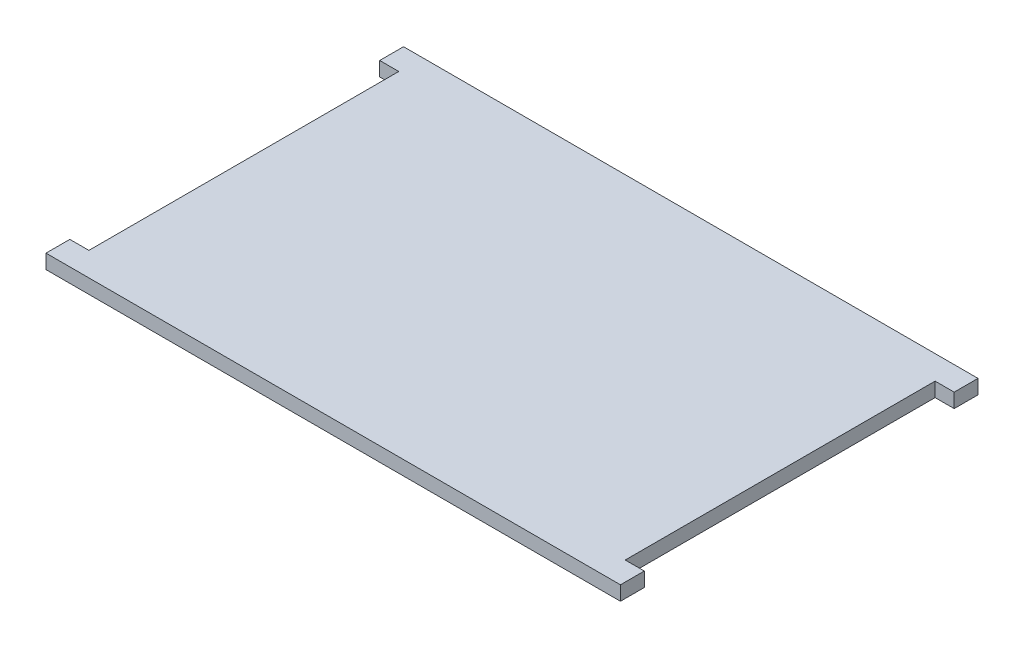
from build123d import *

# Parameters (mm, degrees)
BOSS_EXTRUDE1_DEPTH = 6


with BuildPart() as part:
    # Sketch1 → Boss-Extrude1 (new body)
    with BuildSketch(Plane(origin=(0, 0, 0), x_dir=(1, 0, 0), z_dir=(0, 1, 0))):
        Polygon((-120.5, 75), (120.5, 75), (120.5, 65), (112.5, 65), (112.5, -65), (120.5, -65), (120.5, -75), (-120.5, -75), (-120.5, -65), (-112.5, -65), (-112.5, 65), (-120.5, 65), align=None)
    extrude(amount=BOSS_EXTRUDE1_DEPTH)


solid = part.part
